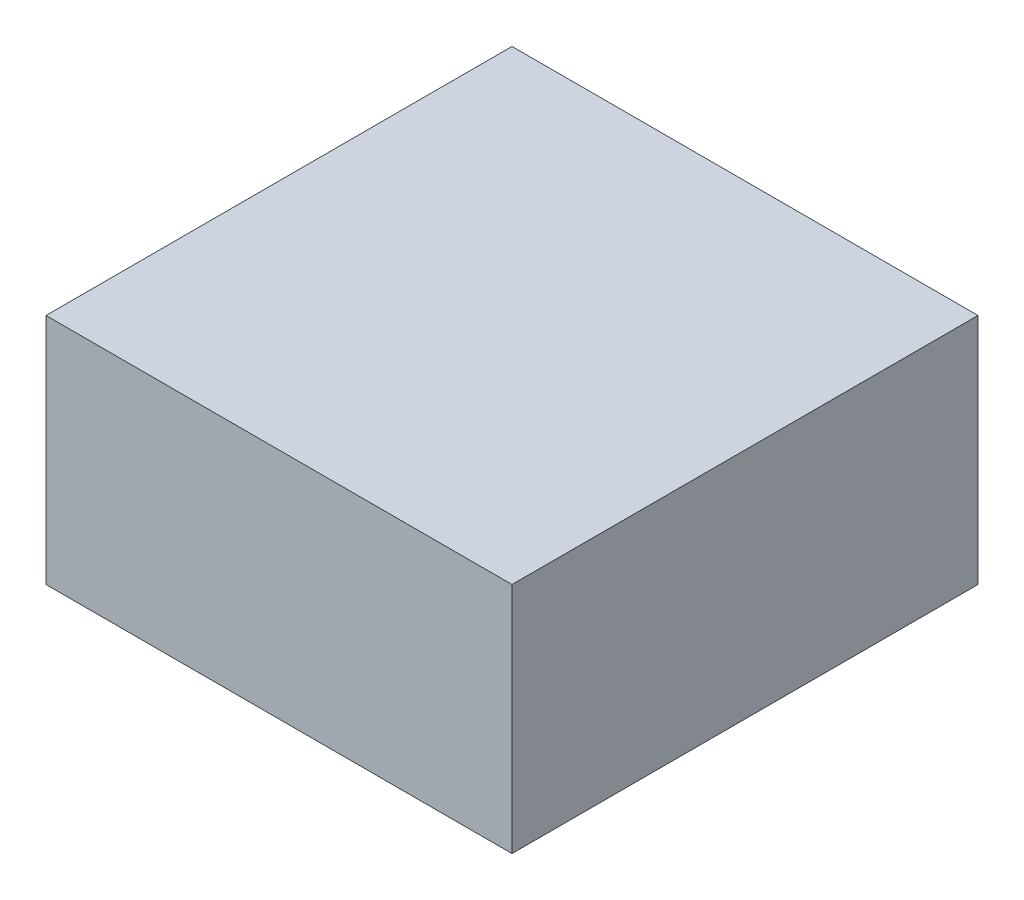
from build123d import *

# Parameters (mm, degrees)
SKIZZE1_W                       = 1
SKIZZE1_H                       = 0.5
AUFSATZ_LINEAR_AUSTRAGEN1_DEPTH = 0.5


with BuildPart() as part:
    # Skizze1 → Aufsatz-Linear austragen1 (new body, symmetric)
    with BuildSketch(Plane(origin=(0, 0, 0), x_dir=(0, 0, -1), z_dir=(1, 0, 0))):
        with Locations((0, -0.25)):
            Rectangle(SKIZZE1_W, SKIZZE1_H)
    extrude(amount=AUFSATZ_LINEAR_AUSTRAGEN1_DEPTH, both=True)


solid = part.part
